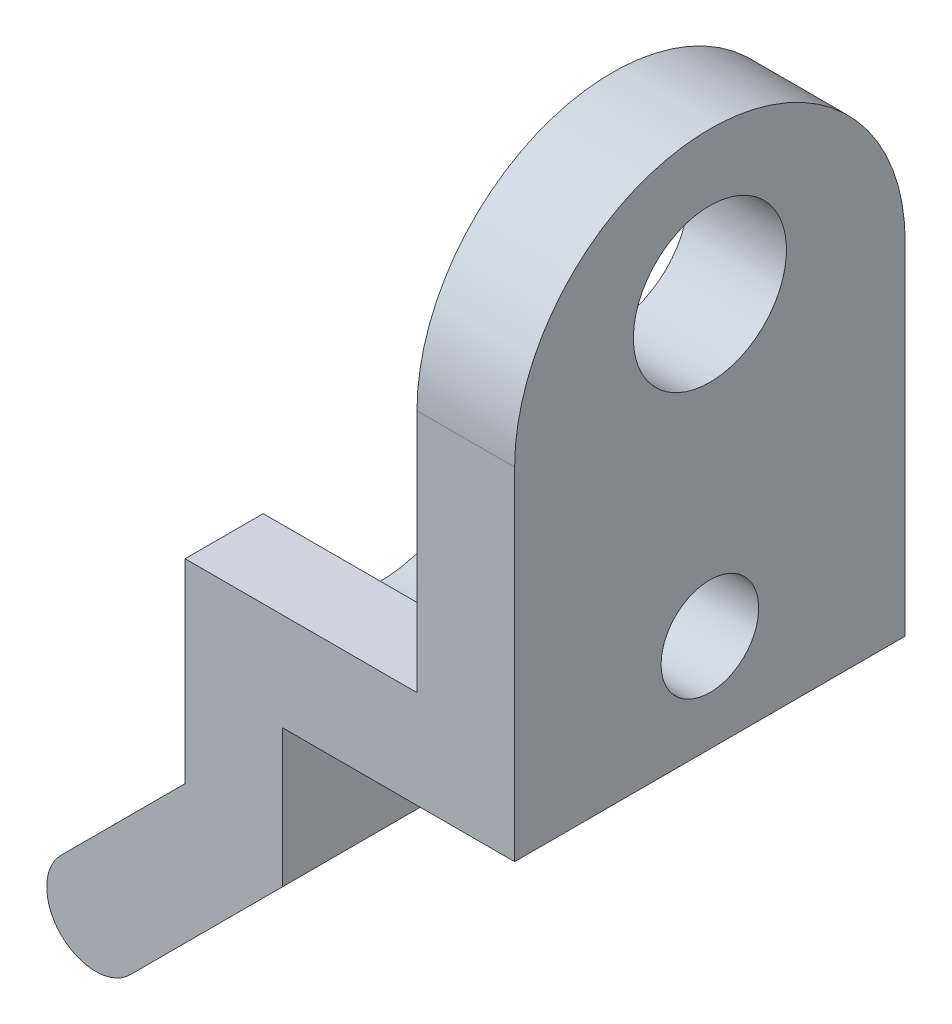
from build123d import *

# Parameters (mm, degrees)
BOSS_EXTRUDE1_DEPTH     = 6.35
SKETCH3_R               = 1.5875
CUT_EXTRUDE1_DEPTH      = 12.696129591
CUT_EXTRUDE1_DEPTH_BACK = 11.834286606
SKETCH4_W               = 3.175
SKETCH4_H               = 7.9375
BOSS_EXTRUDE3_DEPTH     = 6.35
SKETCH5_R               = 3.81
CUT_EXTRUDE2_DEPTH      = 7.540625
SKETCH6_R               = 1.5875
CUT_EXTRUDE3_DEPTH      = 15.2875
SKETCH7_W               = 3.571875
SKETCH7_H               = 3.175
CUT_EXTRUDE4_DEPTH      = 13.7
BOSS_EXTRUDE4_DEPTH     = 3.175
CUT_EXTRUDE5_DEPTH      = 13.039014125
CUT_EXTRUDE5_DEPTH_BACK = 4.175


with BuildPart() as part:
    # Sketch2 → Boss-Extrude1 (new body, symmetric)
    with BuildSketch(Plane.XY):
        with BuildLine():
            Line((-14.2875, -1.570977871), (-18.32092114, -5.604399011))
            ThreePointArc((-18.32092114, -5.604399011), (-18.32092114, -7.849463042), (-16.07585711, -7.849463042))
            Line((-16.07585711, -7.849463042), (-11.1125, -2.886105932))
            Line((-11.1125, -2.886105932), (-11.1125, 1.5875))
            Line((-11.1125, 1.5875), (0, 1.5875))
            Line((0, 1.5875), (0, 4.7625))
            Line((0, 4.7625), (-14.2875, 4.7625))
            Line((-14.2875, 4.7625), (-14.2875, -1.570977871))
        make_face()
    extrude(amount=BOSS_EXTRUDE1_DEPTH, both=True)

    # Sketch3 → Cut-Extrude1 (cut, two sides)
    with BuildSketch(Plane(origin=(-4.113197034, 4.113197034, 0), x_dir=(0, 0, -1), z_dir=(0.707106781, -0.707106781, 0))) as cut_extrude1_sk:
        with Locations((0, -13.742756121)):
            Circle(SKETCH3_R)
    extrude(amount=CUT_EXTRUDE1_DEPTH, mode=Mode.SUBTRACT)
    extrude(cut_extrude1_sk.sketch, amount=-CUT_EXTRUDE1_DEPTH_BACK, mode=Mode.SUBTRACT)

    # Sketch4 → Boss-Extrude3 (add, symmetric)
    with BuildSketch(Plane.XY):
        with Locations((-5.159375, 5.55625)):
            Rectangle(SKETCH4_W, SKETCH4_H)
    extrude(amount=BOSS_EXTRUDE3_DEPTH, both=True)

    # Sketch5 → Cut-Extrude2 (cut)
    with BuildSketch(Plane.ZY.offset(14.2875)):
        with Locations((0, 4.7625)):
            Circle(SKETCH5_R)
    extrude(amount=-CUT_EXTRUDE2_DEPTH, mode=Mode.SUBTRACT)

    # Sketch6 → Cut-Extrude3 (cut, through all)
    with BuildSketch(Plane.ZY.offset(14.2875)):
        with Locations((0, 4.7625)):
            Circle(SKETCH6_R)
    extrude(amount=-CUT_EXTRUDE3_DEPTH, mode=Mode.SUBTRACT)

    # Sketch7 → Cut-Extrude4 (cut, through all)
    with BuildSketch(Plane.XY.offset(6.35)):
        with Locations((-1.7859375, 3.175)):
            Rectangle(SKETCH7_W, SKETCH7_H)
    extrude(amount=-CUT_EXTRUDE4_DEPTH, mode=Mode.SUBTRACT)

    # Sketch8 → Boss-Extrude4 (add)
    with BuildSketch(Plane(origin=(-3.571875, 0, 0), x_dir=(0, 0, -1), z_dir=(1, 0, 0))):
        with BuildLine():
            ThreePointArc((6.35, 12.7), (0, 19.05), (-6.35, 12.7))
            ThreePointArc((-6.35, 12.7), (-6.133628997, 11.056499064), (-5.499261314, 9.525))
            Line((-5.499261314, 9.525), (5.499261314, 9.525))
            ThreePointArc((5.499261314, 9.525), (6.133628997, 11.056499064), (6.35, 12.7))
        make_face()
        with BuildLine():
            Line((5.499261314, 9.525), (-5.499261314, 9.525))
            ThreePointArc((-5.499261314, 9.525), (0, 6.35), (5.499261314, 9.525))
        make_face()
        with BuildLine():
            Line((-6.35, 12.7), (-6.35, 9.525))
            Line((-6.35, 9.525), (-5.499261314, 9.525))
            ThreePointArc((-5.499261314, 9.525), (-6.133628997, 11.056499064), (-6.35, 12.7))
        make_face()
        with BuildLine():
            Line((6.35, 9.525), (6.35, 12.7))
            ThreePointArc((6.35, 12.7), (6.133628997, 11.056499064), (5.499261314, 9.525))
            Line((5.499261314, 9.525), (6.35, 9.525))
        make_face()
    extrude(amount=-BOSS_EXTRUDE4_DEPTH)

    # Sketch9 → Cut-Extrude5 (cut, two sides)
    with BuildSketch(Plane.ZY.offset(6.746875)) as cut_extrude5_sk:
        with BuildLine():
            ThreePointArc((-2.404382567, 13.757225005), (0, 11.912277372), (2.404382567, 13.757225005))
            Line((2.404382567, 13.757225005), (0, 14.401477372))
            Line((0, 14.401477372), (-2.404382567, 13.757225005))
        make_face()
        with BuildLine():
            Line((0, 14.401477372), (2.404382567, 13.757225005))
            ThreePointArc((2.404382567, 13.757225005), (2.467904549, 14.076571574), (2.4892, 14.401477372))
            ThreePointArc((2.4892, 14.401477372), (2.467904549, 14.72638317), (2.404382567, 15.045729739))
            Line((2.404382567, 15.045729739), (0, 14.401477372))
        make_face()
        with BuildLine():
            Line((-2.404382567, 13.757225005), (0, 14.401477372))
            Line((0, 14.401477372), (-2.404382567, 15.045729739))
            ThreePointArc((-2.404382567, 15.045729739), (-2.4892, 14.401477372), (-2.404382567, 13.757225005))
        make_face()
        with BuildLine():
            Line((-2.404382567, 15.045729739), (0, 14.401477372))
            Line((0, 14.401477372), (2.404382567, 15.045729739))
            ThreePointArc((2.404382567, 15.045729739), (0, 16.890677372), (-2.404382567, 15.045729739))
        make_face()
    extrude(amount=CUT_EXTRUDE5_DEPTH, mode=Mode.SUBTRACT)
    extrude(cut_extrude5_sk.sketch, amount=-CUT_EXTRUDE5_DEPTH_BACK, mode=Mode.SUBTRACT)


solid = part.part
